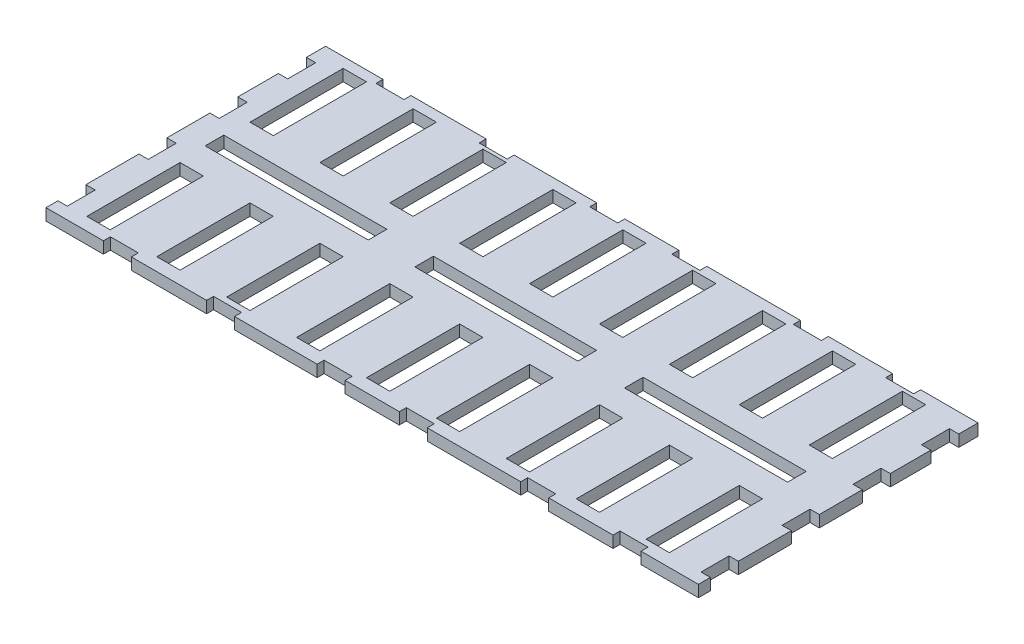
from build123d import *

# Parameters (mm, degrees)
SKETCH1_W           = 280
SKETCH1_H           = 120
BOSS_EXTRUDE1_DEPTH = 5
SKETCH1_3_W         = 10
SKETCH1_3_H         = 40
CUT_EXTRUDE1_DEPTH  = 134
SKETCH1_4_W         = 10
SKETCH1_4_H         = 40
CUT_EXTRUDE2_DEPTH  = 229
SKETCH4_W           = 70
SKETCH4_H           = 8
CUT_EXTRUDE4_DEPTH  = 229
SKETCH3_W           = 4
SKETCH3_H           = 12
SKETCH3_W_2         = 12
SKETCH3_H_2         = 3
CUT_EXTRUDE5_DEPTH  = 10


with BuildPart() as part:
    # Sketch1 → Boss-Extrude1 (new body)
    with BuildSketch(Plane(origin=(0, 0, 0), x_dir=(1, 0, 0), z_dir=(0, 1, 0))):
        with Locations((140, 60)):
            Rectangle(SKETCH1_W, SKETCH1_H)
    extrude(amount=BOSS_EXTRUDE1_DEPTH)

    # Sketch1_3 → Cut-Extrude1 (cut)
    with BuildSketch(Plane(origin=(0, 0, 0), x_dir=(1, 0, 0), z_dir=(0, 1, 0))):
        with Locations((47, 95.54438009)):
            Rectangle(SKETCH1_3_W, SKETCH1_3_H)
        with Locations((77, 95.54438009)):
            Rectangle(SKETCH1_3_W, SKETCH1_3_H)
        with Locations((107, 95.54438009)):
            Rectangle(SKETCH1_3_W, SKETCH1_3_H)
        with Locations((137, 95.54438009)):
            Rectangle(SKETCH1_3_W, SKETCH1_3_H)
        with Locations((167, 95.54438009)):
            Rectangle(SKETCH1_3_W, SKETCH1_3_H)
        with Locations((47, 25.54438009)):
            Rectangle(SKETCH1_3_W, SKETCH1_3_H)
        with Locations((77, 25.54438009)):
            Rectangle(SKETCH1_3_W, SKETCH1_3_H)
        with Locations((107, 25.54438009)):
            Rectangle(SKETCH1_3_W, SKETCH1_3_H)
        with Locations((137, 25.54438009)):
            Rectangle(SKETCH1_3_W, SKETCH1_3_H)
        with Locations((167, 25.54438009)):
            Rectangle(SKETCH1_3_W, SKETCH1_3_H)
        with Locations((17, 25.54438009)):
            Rectangle(SKETCH1_3_W, SKETCH1_3_H)
        with Locations((197, 95.54438009)):
            Rectangle(SKETCH1_3_W, SKETCH1_3_H)
        with Locations((227, 95.54438009)):
            Rectangle(SKETCH1_3_W, SKETCH1_3_H)
        with Locations((257, 95.54438009)):
            Rectangle(SKETCH1_3_W, SKETCH1_3_H)
        with Locations((197, 25.54438009)):
            Rectangle(SKETCH1_3_W, SKETCH1_3_H)
        with Locations((227, 25.54438009)):
            Rectangle(SKETCH1_3_W, SKETCH1_3_H)
        with Locations((257, 25.54438009)):
            Rectangle(SKETCH1_3_W, SKETCH1_3_H)
    extrude(amount=CUT_EXTRUDE1_DEPTH, mode=Mode.SUBTRACT)

    # Sketch1_4 → Cut-Extrude2 (cut)
    with BuildSketch(Plane(origin=(0, 0, 0), x_dir=(1, 0, 0), z_dir=(0, 1, 0))):
        with Locations((17, 95.54438009)):
            Rectangle(SKETCH1_4_W, SKETCH1_4_H)
    extrude(amount=CUT_EXTRUDE2_DEPTH, mode=Mode.SUBTRACT)

    # Sketch4 → Cut-Extrude4 (cut)
    with BuildSketch(Plane(origin=(0, 5, 0), x_dir=(1, 0, 0), z_dir=(0, 1, 0))):
        with Locations((136.177664652, 61.117706899)):
            Rectangle(SKETCH4_W, SKETCH4_H)
        with Locations((46.177664652, 61.117706899)):
            Rectangle(SKETCH4_W, SKETCH4_H)
        with Locations((226.177664652, 61.117706899)):
            Rectangle(SKETCH4_W, SKETCH4_H)
    extrude(amount=-CUT_EXTRUDE4_DEPTH, mode=Mode.SUBTRACT)

    # Sketch3 → Cut-Extrude5 (cut)
    with BuildSketch(Plane(origin=(0, 5, 0), x_dir=(1, 0, 0), z_dir=(0, 1, 0))):
        with Locations((2, 105.740728373)):
            Rectangle(SKETCH3_W, SKETCH3_H)
        with Locations((2, 76.34695717)):
            Rectangle(SKETCH3_W, SKETCH3_H)
        with Locations((2, 45.895590182)):
            Rectangle(SKETCH3_W, SKETCH3_H)
        with Locations((2, 11.128497482)):
            Rectangle(SKETCH3_W, SKETCH3_H)
        with Locations((278, 11.128497482)):
            Rectangle(SKETCH3_W, SKETCH3_H)
        with Locations((278, 45.895590182)):
            Rectangle(SKETCH3_W, SKETCH3_H)
        with Locations((278, 76.34695717)):
            Rectangle(SKETCH3_W, SKETCH3_H)
        with Locations((278, 105.740728373)):
            Rectangle(SKETCH3_W, SKETCH3_H)
        with Locations((157.627034087, 118.5)):
            Rectangle(SKETCH3_W_2, SKETCH3_H_2)
        with Locations((30.63115044, 118.5)):
            Rectangle(SKETCH3_W_2, SKETCH3_H_2)
        with Locations((122.372965913, 118.5)):
            Rectangle(SKETCH3_W_2, SKETCH3_H_2)
        with Locations((249.36884956, 118.5)):
            Rectangle(SKETCH3_W_2, SKETCH3_H_2)
        with Locations((249.36884956, 1.5)):
            Rectangle(SKETCH3_W_2, SKETCH3_H_2)
        with Locations((157.627034087, 1.5)):
            Rectangle(SKETCH3_W_2, SKETCH3_H_2)
        with Locations((122.372965913, 1.5)):
            Rectangle(SKETCH3_W_2, SKETCH3_H_2)
        with Locations((30.63115044, 1.5)):
            Rectangle(SKETCH3_W_2, SKETCH3_H_2)
        with Locations((209.75390842, 118.5)):
            Rectangle(SKETCH3_W_2, SKETCH3_H_2)
        with Locations((74.910678106, 1.5)):
            Rectangle(SKETCH3_W_2, SKETCH3_H_2)
        with Locations((209.75390842, 1.5)):
            Rectangle(SKETCH3_W_2, SKETCH3_H_2)
        with Locations((74.910678106, 118.5)):
            Rectangle(SKETCH3_W_2, SKETCH3_H_2)
    extrude(amount=-CUT_EXTRUDE5_DEPTH, mode=Mode.SUBTRACT)


solid = part.part
